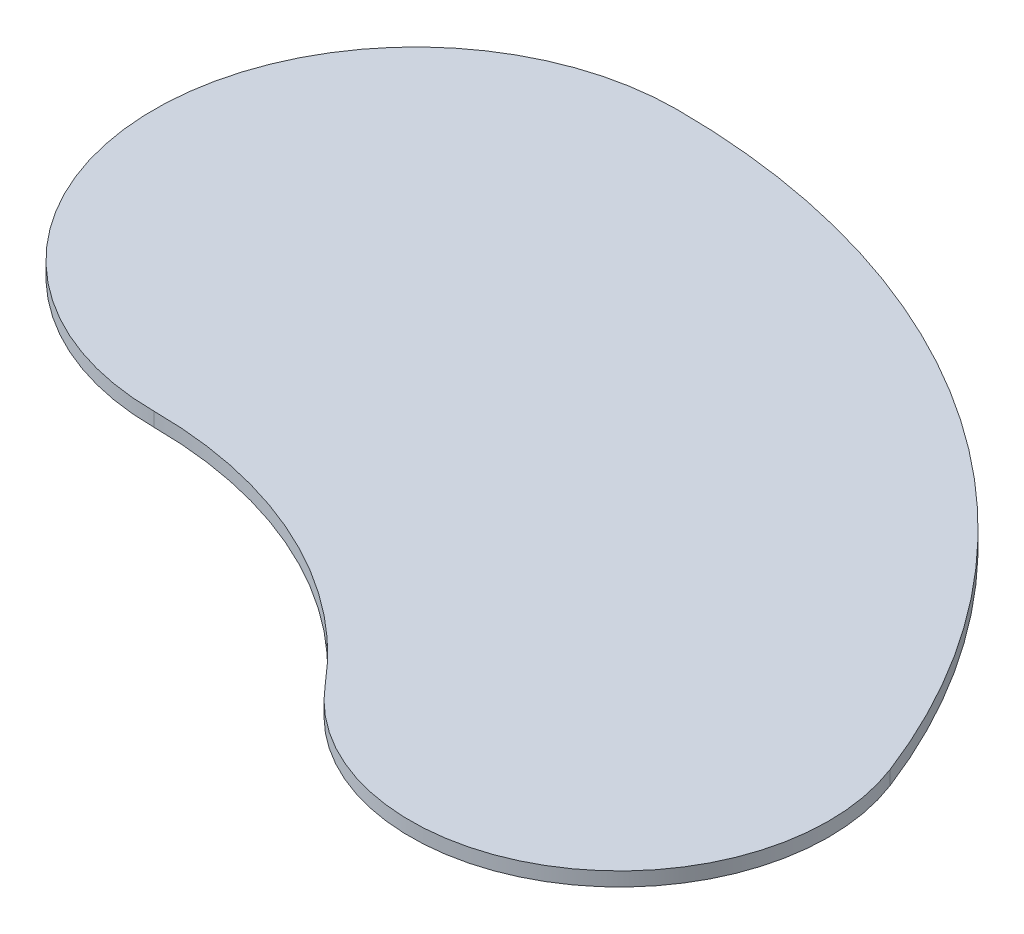
from build123d import *

# Parameters (mm, degrees)
BOSS_EXTRUDE1_DEPTH = 2.54


with BuildPart() as part:
    # Sketch1 → Boss-Extrude1 (new body)
    with BuildSketch(Plane(origin=(0, 0, 0), x_dir=(1, 0, 0), z_dir=(0, 1, 0))):
        with BuildLine():
            ThreePointArc((0, 149.225), (-47.625, 101.6), (0, 53.975))
            ThreePointArc((0, 53.975), (32.413352769, 46.750206264), (58.69008873, 26.443649947))
            ThreePointArc((58.69008873, 26.443649947), (107.287675463, 17.94974103), (123.526365743, 64.53489814))
            ThreePointArc((123.526365743, 64.53489814), (74.885206127, 126.019326735), (0, 149.225))
        make_face()
    extrude(amount=BOSS_EXTRUDE1_DEPTH)


solid = part.part
